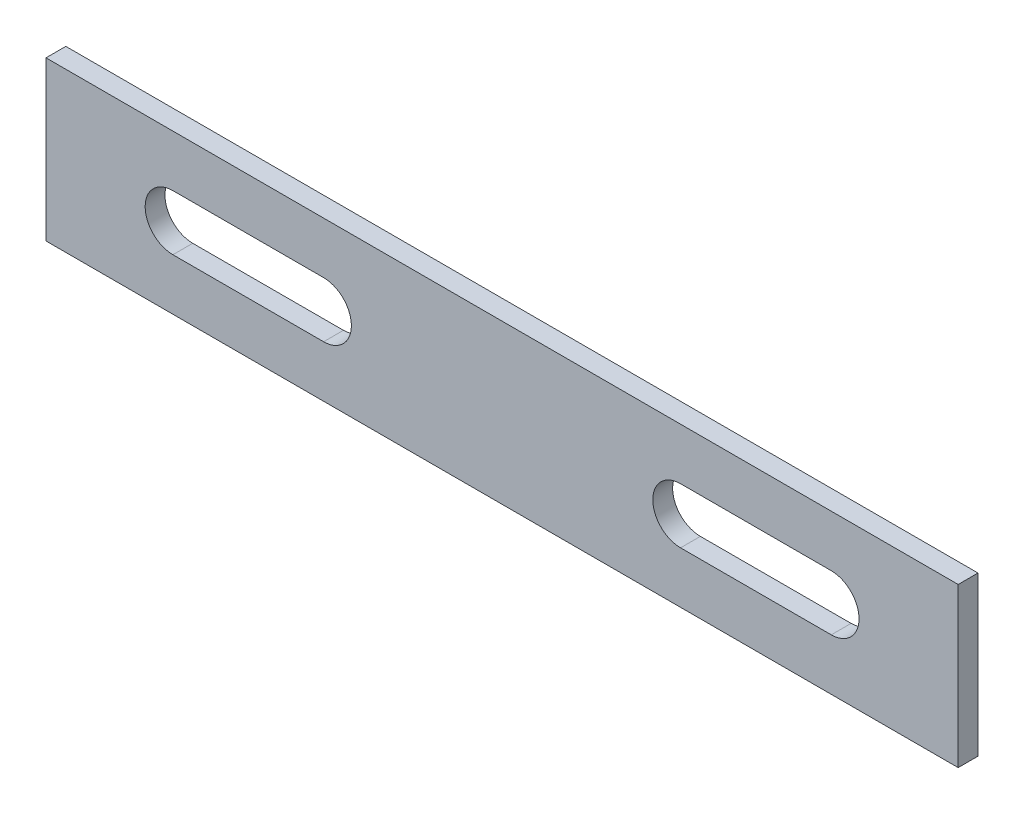
from build123d import *

# Parameters (mm, degrees)
PLAT_W                       = 40
PLAT_H                       = 5
EL_MENT_M_CANO_SOUD_1_DEPTH  = 230
ENL_V_MAT_EXTRU_1_DEPTH      = 3.5
ENL_V_MAT_EXTRU_1_DEPTH_BACK = 3.5


with BuildPart() as part:
    # plat → Elément mécano-soudé1 (new body)
    with BuildSketch(Plane.YZ.offset(-115)):
        Rectangle(PLAT_W, PLAT_H)
    extrude(amount=EL_MENT_M_CANO_SOUD_1_DEPTH)

    # Esquisse2 → Enlèv. mat.-Extru.1 (cut, two sides)
    with BuildSketch(Plane.XY) as enl_v_mat_extru_1_sk:
        with BuildLine():
            Line((-83, 7), (-45, 7))
            ThreePointArc((-45, 7), (-38, 0), (-45, -7))
            Line((-45, -7), (-83, -7))
            ThreePointArc((-83, -7), (-90, 0), (-83, 7))
        make_face()
        with BuildLine():
            Line((83, 7), (45, 7))
            ThreePointArc((45, 7), (38, 0), (45, -7))
            Line((45, -7), (83, -7))
            ThreePointArc((83, -7), (90, 0), (83, 7))
        make_face()
    extrude(amount=ENL_V_MAT_EXTRU_1_DEPTH, mode=Mode.SUBTRACT)
    extrude(enl_v_mat_extru_1_sk.sketch, amount=-ENL_V_MAT_EXTRU_1_DEPTH_BACK, mode=Mode.SUBTRACT)


solid = part.part
